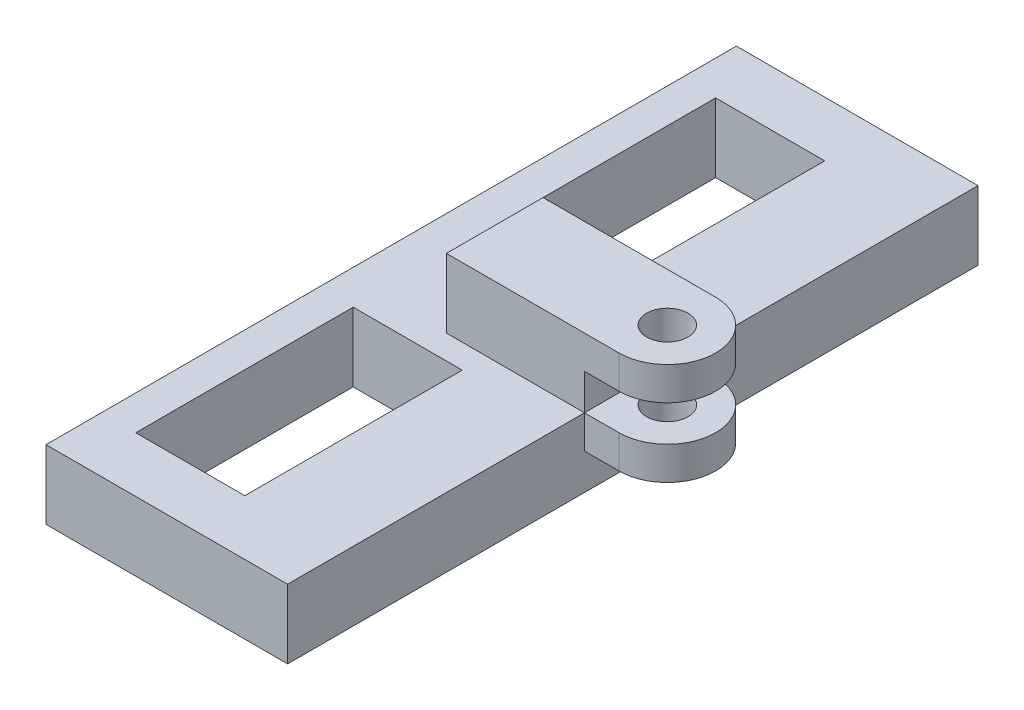
from build123d import *

# Parameters (mm, degrees)
SKETCH1_W                = 44.45
SKETCH1_H                = 127
SKETCH1_W_2              = 20.060000012
SKETCH1_H_2              = 40.00000001
BOSS_EXTRUDE1_DEPTH      = 12.7
BOSS_EXTRUDE2_DEPTH      = 12.7
BOSS_EXTRUDE2_DEPTH_BACK = 12.7
SKETCH2_R                = 3.81
SKETCH3_W                = 15.24
SKETCH3_H                = 6.604
CUT_EXTRUDE1_DEPTH       = 23.114


with BuildPart() as part:
    # Sketch1 → Boss-Extrude1 (new body)
    with BuildSketch(Plane(origin=(0, 0, 0), x_dir=(1, 0, 0), z_dir=(0, 1, 0))):
        Rectangle(SKETCH1_W, SKETCH1_H)
        with Locations((-5.844999994, 33.339999995)):
            Rectangle(SKETCH1_W_2, SKETCH1_H_2, mode=Mode.SUBTRACT)
        with Locations((-5.844999994, -33.339999995)):
            Rectangle(SKETCH1_W_2, SKETCH1_H_2, mode=Mode.SUBTRACT)
    extrude(amount=BOSS_EXTRUDE1_DEPTH)

    # Sketch2 → Boss-Extrude2 (add, two sides: drawn at the far end of the back side and taken through both)
    with BuildSketch(Plane(origin=(0, 12.7, 0), x_dir=(1, 0, 0), z_dir=(0, 1, 0)).offset(-BOSS_EXTRUDE2_DEPTH_BACK)):
        with BuildLine():
            Line((28.575, 8.89), (-3.175, 8.89))
            Line((-3.175, 8.89), (-3.175, -8.89))
            Line((-3.175, -8.89), (28.575, -8.89))
            ThreePointArc((28.575, -8.89), (37.465, 0), (28.575, 8.89))
        make_face()
        with Locations((28.575, 0)):
            Circle(SKETCH2_R, mode=Mode.SUBTRACT)
    extrude(amount=BOSS_EXTRUDE2_DEPTH + BOSS_EXTRUDE2_DEPTH_BACK)

    # Sketch3 → Cut-Extrude1 (cut)
    with BuildSketch(Plane.XY.offset(8.89)):
        with Locations((29.845, 16.002)):
            Rectangle(SKETCH3_W, SKETCH3_H)
        with Locations((29.845, 3.302)):
            Rectangle(SKETCH3_W, SKETCH3_H)
    extrude(amount=-CUT_EXTRUDE1_DEPTH, mode=Mode.SUBTRACT)


solid = part.part
